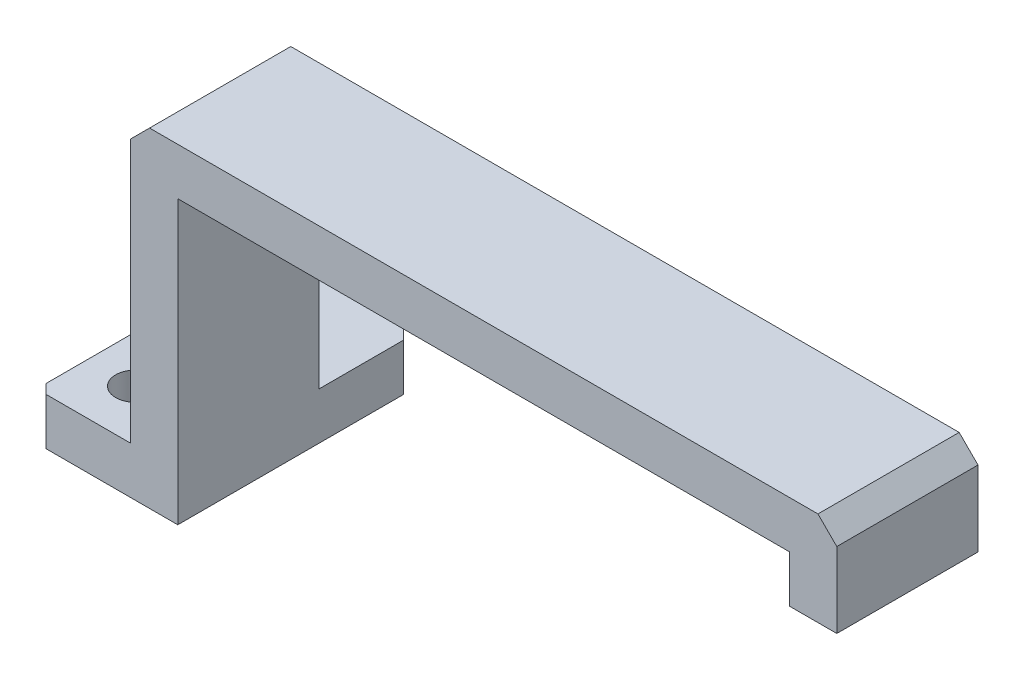
from build123d import *

# Parameters (mm, degrees)
BOSS_EXTRUDE1_DEPTH     = 30
SKETCH2_W               = 50
SKETCH2_H               = 20
CUT_EXTRUDE1_DEPTH      = 30
CHAMFER1_SIZE           = 2
SKETCH3_R               = 2.1
CUT_EXTRUDE2_DEPTH      = 30
SKETCH6_W               = 5
SKETCH6_H               = 30
BOSS_EXTRUDE2_DEPTH     = 5
SKETCH7_W               = 126.18944296
SKETCH7_H               = 49.64624499
CUT_EXTRUDE3_DEPTH      = 15
SKETCH8_W               = 20
SKETCH8_H               = 15
BOSS_EXTRUDE3_DEPTH     = 5
SKETCH9_W               = 71
SKETCH9_H               = 15
BOSS_EXTRUDE4_DEPTH     = 5
SKETCH10_W              = 15
SKETCH10_H              = 20
SKETCH10_H_2            = 5
CUT_EXTRUDE4_DEPTH      = 38
CUT_EXTRUDE4_DEPTH_BACK = 27
SKETCH11_R              = 2.1
CUT_EXTRUDE5_DEPTH      = 27
SKETCH12_R              = 2.1
BOSS_EXTRUDE5_DEPTH     = 5
SKETCH13_R              = 2.1
CUT_EXTRUDE6_DEPTH      = 5
SKETCH14_W              = 5
SKETCH14_H              = 15
CUT_EXTRUDE7_DEPTH      = 10
SKETCH15_W              = 5
SKETCH15_H              = 15
CUT_EXTRUDE8_DEPTH      = 10
SKETCH16_W              = 10
SKETCH16_H              = 25
BOSS_EXTRUDE6_DEPTH     = 5
SKETCH17_R              = 2.1
CUT_EXTRUDE9_DEPTH      = 30
SKETCH18_W              = 10
SKETCH18_H              = 5
BOSS_EXTRUDE7_DEPTH     = 5
CHAMFER3_SIZE           = 1
CHAMFER4_SIZE           = 1


with BuildPart() as part:
    # Sketch1 → Boss-Extrude1 (new body)
    with BuildSketch(Plane.XY):
        Polygon((-57.5, -17.5), (-37.5, -17.5), (-32.5, -17.5), (-32.5, 12.5), (32.5, 12.5), (32.5, -17.5), (37.5, -17.5), (57.5, -17.5), (57.5, -12.5), (37.5, -12.5), (37.5, 17.5), (-37.5, 17.5), (-37.5, -12.5), (-57.5, -12.5), align=None)
    extrude(amount=BOSS_EXTRUDE1_DEPTH)

    # Sketch2 → Cut-Extrude1 (cut)
    with BuildSketch(Plane(origin=(0, 17.5, 0), x_dir=(1, 0, 0), z_dir=(0, 1, 0))):
        with Locations((0, -15)):
            Rectangle(SKETCH2_W, SKETCH2_H)
    extrude(amount=-CUT_EXTRUDE1_DEPTH, mode=Mode.SUBTRACT)

    # Chamfer1
    chamfer1_edges = [part.edges().sort_by_distance(p)[0] for p in [
        (-37.5, 17.5, 15),
        (37.5, 17.5, 15),
    ]]
    chamfer(chamfer1_edges, length=CHAMFER1_SIZE)

    # Sketch3 → Cut-Extrude2 (cut)
    with BuildSketch(Plane(origin=(0, -12.5, 0), x_dir=(1, 0, 0), z_dir=(0, 1, 0))):
        with Locations((-47.5, -15)):
            Circle(SKETCH3_R)
        with Locations((47.5, -15)):
            Circle(SKETCH3_R)
    extrude(amount=-CUT_EXTRUDE2_DEPTH, mode=Mode.SUBTRACT)

    # Sketch6 → Boss-Extrude2 (add)
    with BuildSketch(Plane(origin=(0, 17.5, 0), x_dir=(1, 0, 0), z_dir=(0, 1, 0))):
        with Locations((0, -15)):
            Rectangle(SKETCH6_W, SKETCH6_H)
    extrude(amount=-BOSS_EXTRUDE2_DEPTH)

    # Sketch7 → Cut-Extrude3 (cut)
    with BuildSketch(Plane.XY.offset(30)):
        Rectangle(SKETCH7_W, SKETCH7_H)
    extrude(amount=-CUT_EXTRUDE3_DEPTH, mode=Mode.SUBTRACT)

    # Sketch8 → Boss-Extrude3 (add, through all)
    with BuildSketch(Plane(origin=(0, -12.5, 0), x_dir=(1, 0, 0), z_dir=(0, 1, 0))):
        with Locations((-47.5, -7.5)):
            Rectangle(SKETCH8_W, SKETCH8_H)
    extrude(amount=-BOSS_EXTRUDE3_DEPTH)

    # Sketch9 → Boss-Extrude4 (add)
    with BuildSketch(Plane(origin=(0, 17.5, 0), x_dir=(1, 0, 0), z_dir=(0, 1, 0))):
        with Locations((0, -7.5)):
            Rectangle(SKETCH9_W, SKETCH9_H)
    extrude(amount=-BOSS_EXTRUDE4_DEPTH)

    # Sketch10 → Cut-Extrude4 (cut, two sides)
    with BuildSketch(Plane(origin=(37.5, 0, 0), x_dir=(0, 0, -1), z_dir=(1, 0, 0))) as cut_extrude4_sk:
        with Locations((-7.5, -2.5)):
            Rectangle(SKETCH10_W, SKETCH10_H)
        with Locations((-7.5, -15)):
            Rectangle(SKETCH10_W, SKETCH10_H_2)
    extrude(amount=CUT_EXTRUDE4_DEPTH, mode=Mode.SUBTRACT)
    extrude(cut_extrude4_sk.sketch, amount=-CUT_EXTRUDE4_DEPTH_BACK, mode=Mode.SUBTRACT)

    # Sketch11 → Cut-Extrude5 (cut)
    with BuildSketch(Plane(origin=(0, -12.5, 0), x_dir=(1, 0, 0), z_dir=(0, 1, 0))):
        with Locations((-47.5, -7.5)):
            Circle(SKETCH11_R)
    extrude(amount=-CUT_EXTRUDE5_DEPTH, mode=Mode.SUBTRACT)

    # Sketch12 → Boss-Extrude5 (add)
    with BuildSketch(Plane(origin=(0, -17.5, 0), x_dir=(-1, 0, 0), z_dir=(0, -1, 0))):
        with Locations((47.5, -7.5)):
            Circle(SKETCH12_R)
    extrude(amount=-BOSS_EXTRUDE5_DEPTH)

    # Sketch13 → Cut-Extrude6 (cut)
    with BuildSketch(Plane(origin=(0, -17.5, 0), x_dir=(-1, 0, 0), z_dir=(0, -1, 0))):
        with Locations((42.5, -11)):
            Circle(SKETCH13_R)
        with Locations((42.5, -4)):
            Circle(SKETCH13_R)
    extrude(amount=-CUT_EXTRUDE6_DEPTH, mode=Mode.SUBTRACT)

    # Sketch14 → Cut-Extrude7 (cut)
    with BuildSketch(Plane(origin=(0, -17.5, 0), x_dir=(-1, 0, 0), z_dir=(0, -1, 0))):
        with Locations((55, -7.5)):
            Rectangle(SKETCH14_W, SKETCH14_H)
    extrude(amount=-CUT_EXTRUDE7_DEPTH, mode=Mode.SUBTRACT)

    # Sketch15 → Cut-Extrude8 (cut)
    with BuildSketch(Plane(origin=(0, -12.5, 0), x_dir=(1, 0, 0), z_dir=(0, 1, 0))):
        with Locations((-50, -7.5)):
            Rectangle(SKETCH15_W, SKETCH15_H)
    extrude(amount=-CUT_EXTRUDE8_DEPTH, mode=Mode.SUBTRACT)

    # Sketch16 → Boss-Extrude6 (add, through all)
    with BuildSketch(Plane(origin=(0, -12.5, 0), x_dir=(1, 0, 0), z_dir=(0, 1, 0))):
        with Locations((-42.5, -2.5)):
            Rectangle(SKETCH16_W, SKETCH16_H)
    extrude(amount=-BOSS_EXTRUDE6_DEPTH)

    # Sketch17 → Cut-Extrude9 (cut)
    with BuildSketch(Plane(origin=(0, -12.5, 0), x_dir=(1, 0, 0), z_dir=(0, 1, 0))):
        with Locations((-42.5, 4.5)):
            Circle(SKETCH17_R)
        with Locations((-42.5, -9.5)):
            Circle(SKETCH17_R)
    extrude(amount=-CUT_EXTRUDE9_DEPTH, mode=Mode.SUBTRACT)

    # Sketch18 → Boss-Extrude7 (add)
    with BuildSketch(Plane(origin=(-37.5, 0, 0), x_dir=(0, 0, -1), z_dir=(1, 0, 0))):
        with Locations((5, -15)):
            Rectangle(SKETCH18_W, SKETCH18_H)
    extrude(amount=BOSS_EXTRUDE7_DEPTH)

    # Chamfer3
    chamfer3_edges = [part.edges().sort_by_distance(p)[0] for p in [
        (-47.5, -15, 15),
        (-47.5, -15, -10),
    ]]
    chamfer(chamfer3_edges, length=CHAMFER3_SIZE)

    # Chamfer4
    chamfer4_edges = [part.edges().sort_by_distance(p)[0] for p in [
        (-32.5, -15, -10),
    ]]
    chamfer(chamfer4_edges, length=CHAMFER4_SIZE)


solid = part.part
